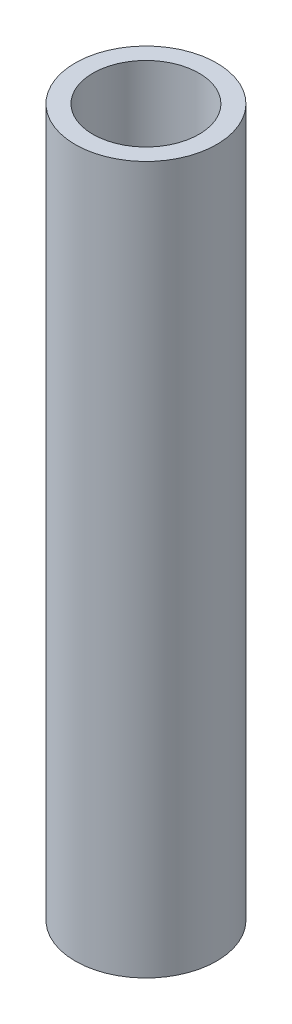
from build123d import *

# Parameters (mm, degrees)
SKETCH1_R           = 10
SKETCH1_R_2         = 7.5
BOSS_EXTRUDE1_DEPTH = 100


with BuildPart() as part:
    # Sketch1 → Boss-Extrude1 (new body)
    with BuildSketch(Plane(origin=(0, 0, 0), x_dir=(1, 0, 0), z_dir=(0, 1, 0))):
        Circle(SKETCH1_R)
        Circle(SKETCH1_R_2, mode=Mode.SUBTRACT)
    extrude(amount=BOSS_EXTRUDE1_DEPTH)


solid = part.part
